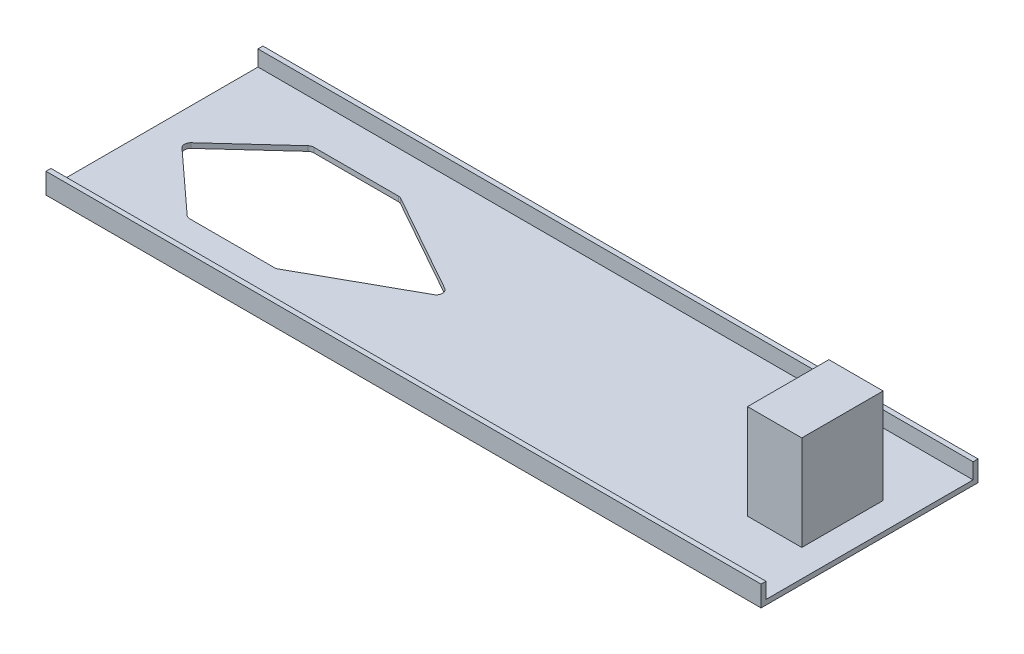
from build123d import *

# Parameters (mm, degrees)
SKETCH1_W           = 669.925
SKETCH1_H           = 203.2
BOSS_EXTRUDE1_DEPTH = 4.6228
SKETCH2_W           = 669.925
SKETCH2_H           = 4.6228
BOSS_EXTRUDE2_DEPTH = 14.732
CUT_EXTRUDE1_DEPTH  = 5.6228
FILLET1_R           = 5.842
SKETCH4_W           = 50.8
SKETCH4_H           = 76.2
BOSS_EXTRUDE3_DEPTH = 88.9


with BuildPart() as part:
    # Sketch1 → Boss-Extrude1 (new body)
    with BuildSketch(Plane(origin=(0, 0, 0), x_dir=(1, 0, 0), z_dir=(0, 1, 0))):
        with Locations((334.9625, 101.6)):
            Rectangle(SKETCH1_W, SKETCH1_H)
    extrude(amount=BOSS_EXTRUDE1_DEPTH)

    # Sketch2 → Boss-Extrude2 (add)
    with BuildSketch(Plane(origin=(0, 4.6228, 0), x_dir=(1, 0, 0), z_dir=(0, 1, 0))):
        with Locations((334.9625, 2.3114)):
            Rectangle(SKETCH2_W, SKETCH2_H)
        with Locations((334.9625, 200.8886)):
            Rectangle(SKETCH2_W, SKETCH2_H)
    extrude(amount=BOSS_EXTRUDE2_DEPTH)

    # Sketch3 → Cut-Extrude1 (cut, through all)
    with BuildSketch(Plane(origin=(0, 4.6228, 0), x_dir=(1, 0, 0), z_dir=(0, 1, 0))):
        Polygon((171.958, 43.4975), (88.9, 43.4975), (25.4, 101.6), (88.9, 159.7025), (171.958, 159.7025), (276.225, 101.3968), align=None)
    extrude(amount=-CUT_EXTRUDE1_DEPTH, mode=Mode.SUBTRACT)

    # Fillet1
    fillet1_edges = [part.edges().sort_by_distance(p)[0] for p in [
        (171.958, 2.3114, -159.7025),
        (276.225, 2.3114, -101.3968),
        (171.958, 2.3114, -43.4975),
        (88.9, 2.3114, -43.4975),
        (25.4, 2.3114, -101.6),
        (88.9, 2.3114, -159.7025),
    ]]
    fillet(fillet1_edges, radius=FILLET1_R)

    # Sketch4 → Boss-Extrude3 (add)
    with BuildSketch(Plane(origin=(0, 4.6228, 0), x_dir=(1, 0, 0), z_dir=(0, 1, 0))):
        with Locations((619.125, 101.6)):
            Rectangle(SKETCH4_W, SKETCH4_H)
    extrude(amount=BOSS_EXTRUDE3_DEPTH)


solid = part.part
